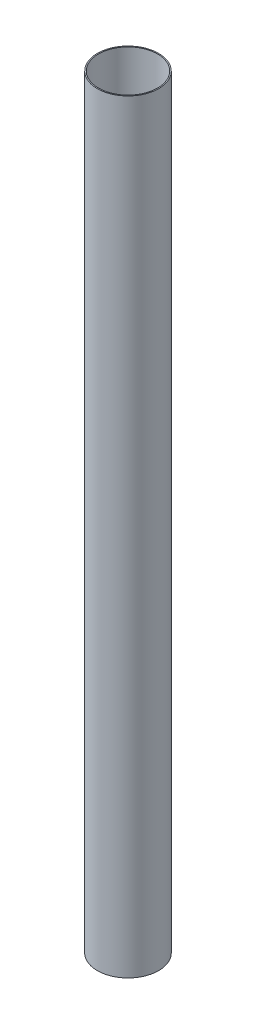
from build123d import *

# Parameters (mm, degrees)
SKETCH1_R           = 42.5
SKETCH1_R_2         = 41
BOSS_EXTRUDE1_DEPTH = 1060


with BuildPart() as part:
    # Sketch1 → Boss-Extrude1 (new body)
    with BuildSketch(Plane(origin=(0, 0, 0), x_dir=(1, 0, 0), z_dir=(0, 1, 0))):
        Circle(SKETCH1_R)
        Circle(SKETCH1_R_2, mode=Mode.SUBTRACT)
    extrude(amount=BOSS_EXTRUDE1_DEPTH)


solid = part.part
